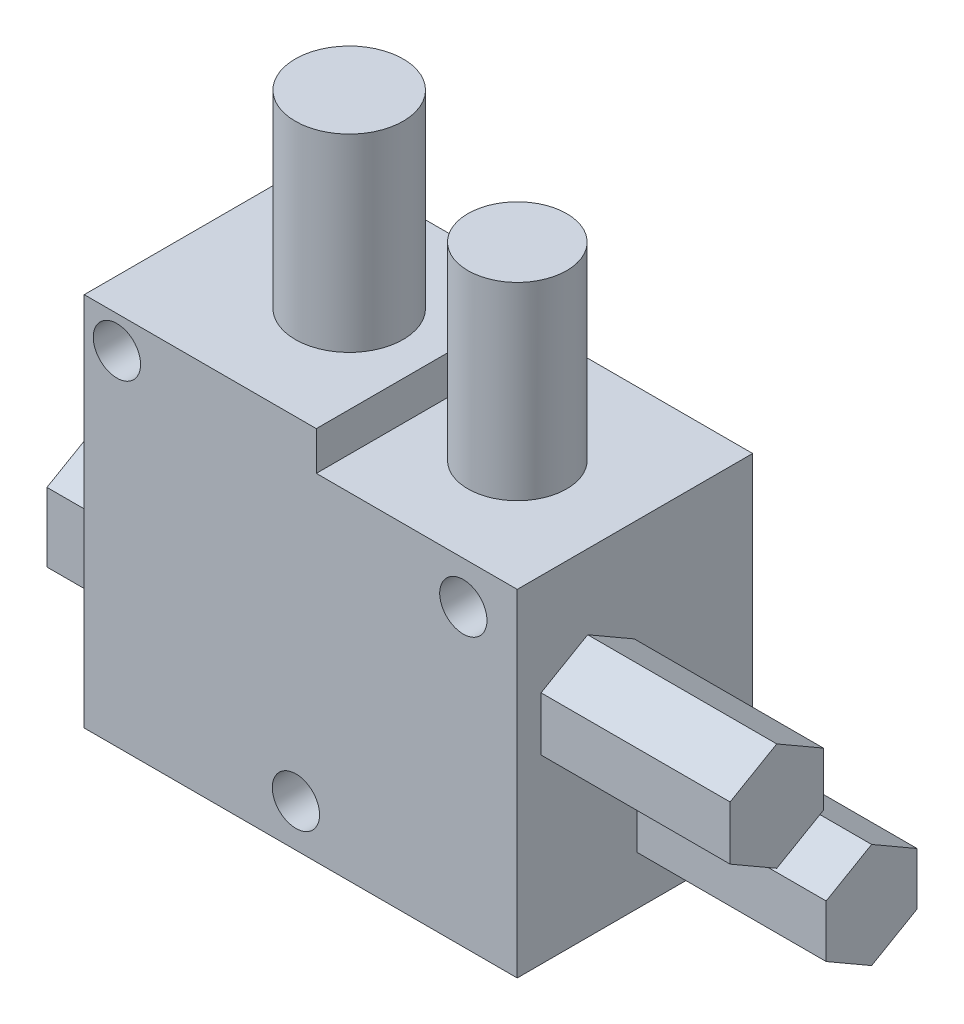
from build123d import *

# Parameters (mm, degrees)
SKETCH1_W           = 45.8
SKETCH1_H           = 39.7
BOSS_EXTRUDE1_DEPTH = 24.9
SKETCH2_W           = 21.252664268
SKETCH2_H           = 4.1
CUT_EXTRUDE1_DEPTH  = 24.9
SKETCH3_R           = 5.707882507
BOSS_EXTRUDE2_DEPTH = 20
SKETCH4_R           = 5.223999668
BOSS_EXTRUDE3_DEPTH = 20
BOSS_EXTRUDE4_DEPTH = 10
BOSS_EXTRUDE5_DEPTH = 20
SKETCH7_R           = 2.5
CUT_EXTRUDE2_DEPTH  = 100


with BuildPart() as part:
    # Sketch1 → Boss-Extrude1 (new body)
    with BuildSketch(Plane.XY):
        with Locations((-66.792592593, 34.14526749)):
            Rectangle(SKETCH1_W, SKETCH1_H)
    extrude(amount=BOSS_EXTRUDE1_DEPTH)

    # Sketch2 → Cut-Extrude1 (cut)
    with BuildSketch(Plane.XY.offset(24.9)):
        with Locations((-54.518924727, 51.94526749)):
            Rectangle(SKETCH2_W, SKETCH2_H)
    extrude(amount=-CUT_EXTRUDE1_DEPTH, mode=Mode.SUBTRACT)

    # Sketch3 → Boss-Extrude2 (add)
    with BuildSketch(Plane(origin=(0, 53.99526749, 0), x_dir=(1, 0, 0), z_dir=(0, 1, 0))):
        with Locations((-74.419404391, -12.144927528)):
            Circle(SKETCH3_R)
    extrude(amount=BOSS_EXTRUDE2_DEPTH)

    # Sketch4 → Boss-Extrude3 (add)
    with BuildSketch(Plane(origin=(0, 49.89526749, 0), x_dir=(1, 0, 0), z_dir=(0, 1, 0))):
        with Locations((-55.701029149, -13.081935835)):
            Circle(SKETCH4_R)
    extrude(amount=BOSS_EXTRUDE3_DEPTH)

    # Sketch5 → Boss-Extrude4 (add)
    with BuildSketch(Plane.ZY.offset(89.692592593)):
        Polygon((18.845976306, 21.012997096), (18.845976306, 28.313544296), (12.523516969, 31.963817896), (6.201057632, 28.313544296), (6.201057632, 21.012997096), (12.523516969, 17.362723496), align=None)
    extrude(amount=BOSS_EXTRUDE4_DEPTH)

    # Sketch6 → Boss-Extrude5 (add)
    with BuildSketch(Plane(origin=(-43.892592593, 0, 0), x_dir=(0, 0, -1), z_dir=(1, 0, 0))):
        Polygon((-17.449153894, 30.618145188), (-12.514917778, 33.466927738), (-12.514917778, 39.164492838), (-17.449153894, 42.013275388), (-22.383390011, 39.164492838), (-22.383390011, 33.466927738), align=None)
        Polygon((-7.414087621, 16.686679556), (-2.60718663, 19.461945137), (-2.60718663, 25.012476299), (-7.414087621, 27.78774188), (-12.220988612, 25.012476299), (-12.220988612, 19.461945137), align=None)
    extrude(amount=BOSS_EXTRUDE5_DEPTH)

    # Sketch7 → Cut-Extrude2 (cut)
    with BuildSketch(Plane.XY.offset(24.9)):
        with Locations((-67.30075544, 18.790910281)):
            Circle(SKETCH7_R)
        with Locations((-86.236984796, 50.57800228)):
            Circle(SKETCH7_R)
        with Locations((-49.59462681, 45.445985012)):
            Circle(SKETCH7_R)
    extrude(amount=-CUT_EXTRUDE2_DEPTH, mode=Mode.SUBTRACT)


solid = part.part
